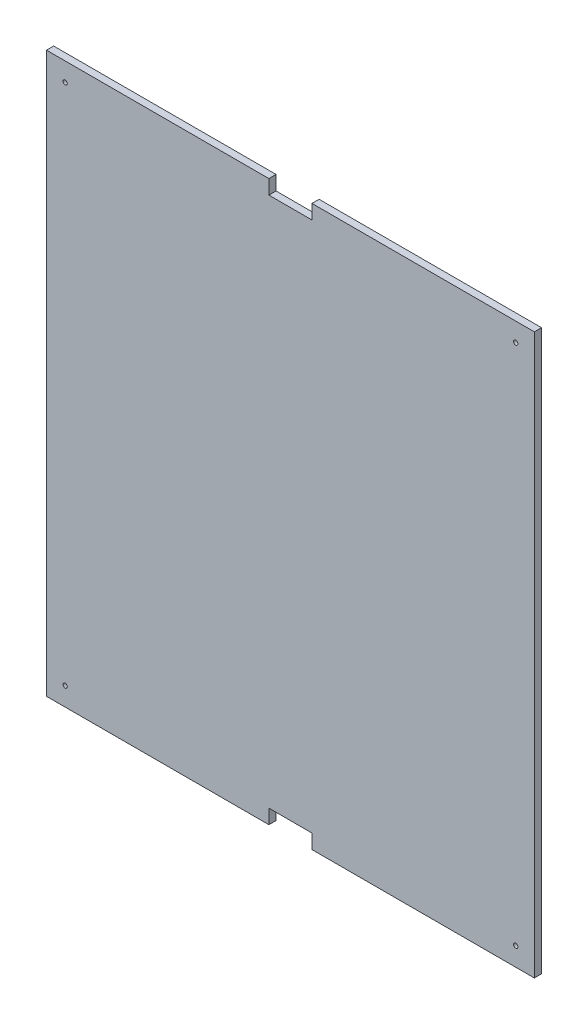
from build123d import *

# Parameters (mm, degrees)
CROQUIS1_R              = 1.5
SALIENTE_EXTRUIR1_DEPTH = 5


with BuildPart() as part:
    # Croquis1 → Saliente-Extruir1 (new body)
    with BuildSketch(Plane.XY):
        Polygon((-108.397386715, -340.463974458), (46.602613285, -340.463974458), (46.602613285, -330.463974458), (76.602613285, -330.463974458), (76.602613285, -340.463974458), (231.602613285, -340.463974458), (231.602613285, 49.536025542), (76.602613285, 49.536025542), (76.602613285, 39.536025542), (46.602613285, 39.536025542), (46.602613285, 49.536025542), (-108.397386715, 49.536025542), align=None)
        with Locations((-95.397386715, -327.463974458)):
            Circle(CROQUIS1_R, mode=Mode.SUBTRACT)
        with Locations((218.602613285, -327.463974458)):
            Circle(CROQUIS1_R, mode=Mode.SUBTRACT)
        with Locations((218.602613285, 36.536025542)):
            Circle(CROQUIS1_R, mode=Mode.SUBTRACT)
        with Locations((-95.397386715, 36.536025542)):
            Circle(CROQUIS1_R, mode=Mode.SUBTRACT)
    extrude(amount=SALIENTE_EXTRUIR1_DEPTH)


solid = part.part
